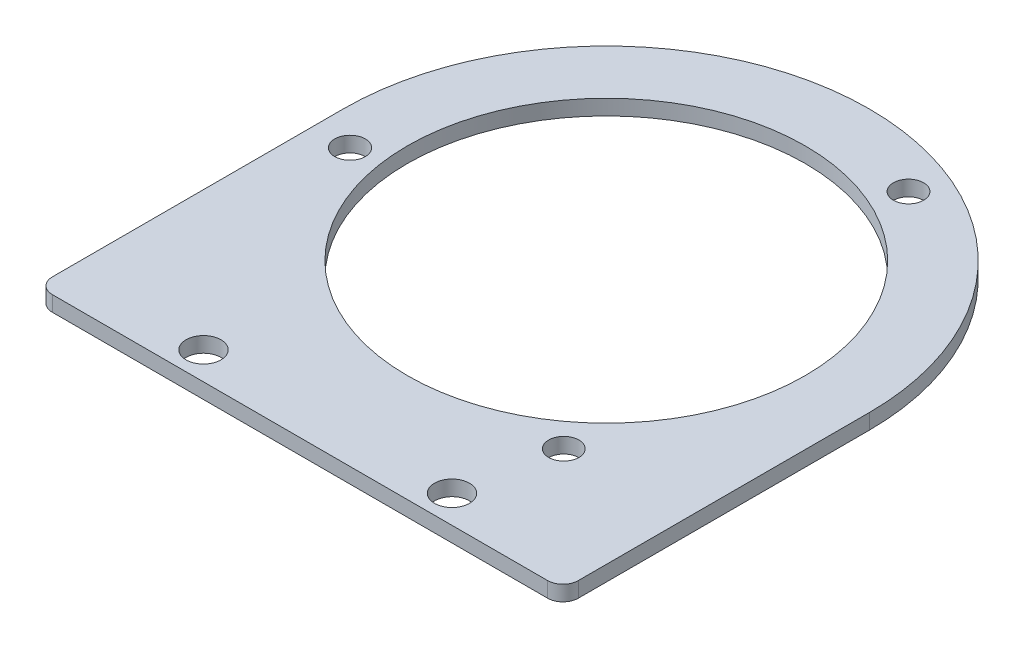
from build123d import *

# Parameters (mm, degrees)
SKETCH4_R           = 82.49431047
SKETCH4_R_2         = 7.246642198
SKETCH4_R_3         = 6.35187519
SKETCH4_R_4         = 6.283502274
SKETCH4_R_5         = 6.278398691
BOSS_EXTRUDE1_DEPTH = 6.35


with BuildPart() as part:
    # Sketch4 → Boss-Extrude1 (new body)
    with BuildSketch(Plane(origin=(0, 0, 0), x_dir=(1, 0, 0), z_dir=(0, 1, 0))):
        with BuildLine():
            Line((-102.682677734, -127), (102.682677734, -127))
            ThreePointArc((102.682677734, -127), (107.172805794, -125.140128061), (109.032677734, -120.65))
            Line((109.032677734, -120.65), (109.032677734, 0))
            ThreePointArc((109.032677734, 0), (0, 109.032677734), (-109.032677734, 0))
            Line((-109.032677734, 0), (-109.032677734, -120.65))
            ThreePointArc((-109.032677734, -120.65), (-107.172805794, -125.140128061), (-102.682677734, -127))
        make_face()
        Circle(SKETCH4_R, mode=Mode.SUBTRACT)
        with Locations((-51.514938753, -115.487351309)):
            Circle(SKETCH4_R_2, mode=Mode.SUBTRACT)
        with Locations((51.514938753, -115.487351309)):
            Circle(SKETCH4_R_2, mode=Mode.SUBTRACT)
        with Locations((-93.682436309, -12.561067561)):
            Circle(SKETCH4_R_3, mode=Mode.SUBTRACT)
        with Locations((37.802843995, 87.500493595)):
            Circle(SKETCH4_R_4, mode=Mode.SUBTRACT)
        with Locations((58.697357769, -76.319875304)):
            Circle(SKETCH4_R_5, mode=Mode.SUBTRACT)
    extrude(amount=BOSS_EXTRUDE1_DEPTH)


solid = part.part
